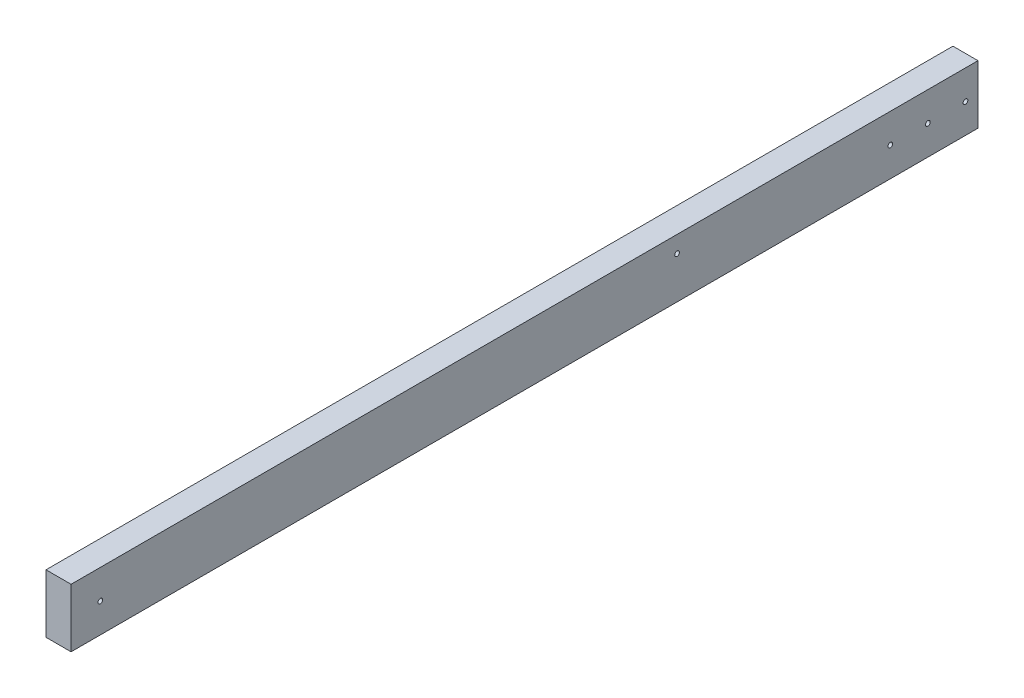
from build123d import *

# Parameters (mm, degrees)
SKETCH1_W                       = 38.1
SKETCH1_H                       = 88.9
BOSS_EXTRUDE1_DEPTH             = 1377.95
F_9_32_0_28125_DIAMETER_HOLE1_D = 7.14375


with BuildPart() as part:
    # Sketch1 → Boss-Extrude1 (new body)
    with BuildSketch(Plane.XY):
        Rectangle(SKETCH1_W, SKETCH1_H)
    extrude(amount=BOSS_EXTRUDE1_DEPTH)

    # 9/32 (0.28125) Diameter Hole1 (through all)
    with Locations(Plane(origin=(19.05, 0, 0), x_dir=(0, 0, -1), z_dir=(1, 0, 0))):
        with Locations((-19.05, 0), (-76.2, 0), (-133.35, 0), (-1333.5, 0), (-457.2, 19.05)):
            Hole(F_9_32_0_28125_DIAMETER_HOLE1_D / 2)


solid = part.part
